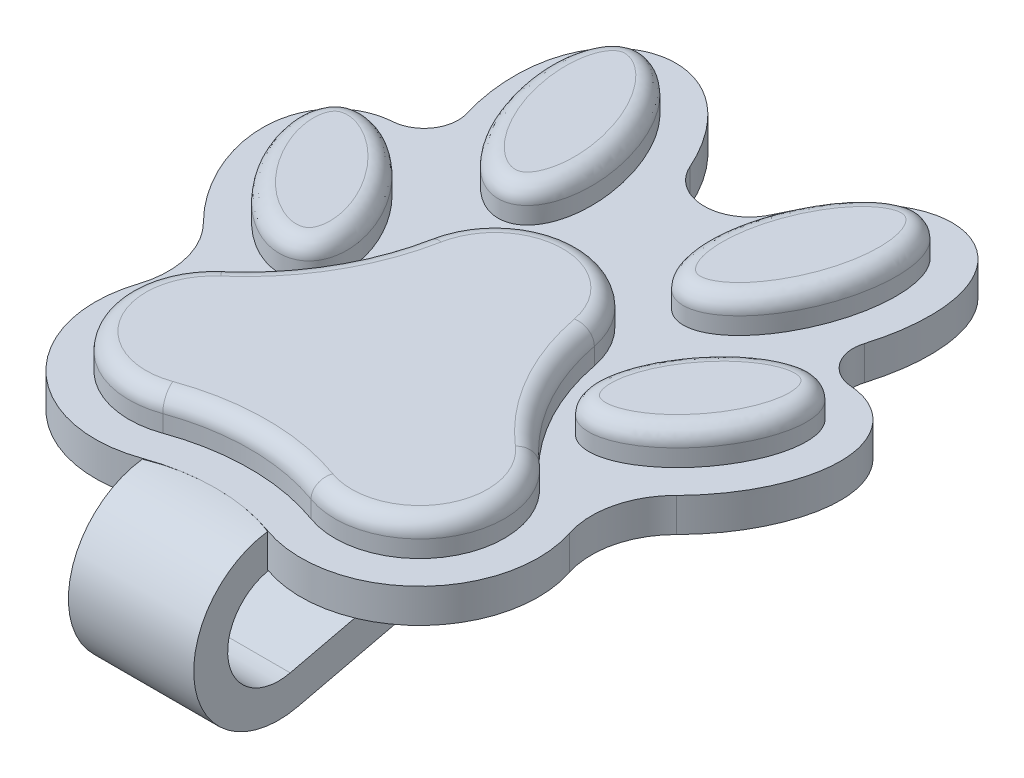
from build123d import *

# Parameters (mm, degrees)
SKETCH3_RX               = 5.238185387
SKETCH3_RY               = 2.857620548
BOSS_EXTRUDE1_DEPTH      = 2
SKETCH3_RX_2             = 5.80398495
SKETCH3_RY_2             = 3.052820099
BOSS_EXTRUDE1_2_DEPTH    = 2
BOSS_EXTRUDE1_3_DEPTH    = 2
BOSS_EXTRUDE1_4_DEPTH    = 2
BOSS_EXTRUDE1_5_DEPTH    = 2
BOSS_EXTRUDE2_DEPTH      = 2
FILLET1_R                = 1
FILLET2_R                = 1
BOSS_EXTRUDE3_DEPTH      = 3.69282
BOSS_EXTRUDE3_DEPTH_BACK = 3.692817


with BuildPart() as part:
    # Sketch3 → Boss-Extrude1 (new body)
    with BuildSketch(Plane(origin=(0, 0, 0), x_dir=(1, 0, 0), z_dir=(0, 1, 0))):
        with Locations(Location((11.150517056, 5.945805234), (0, 0, -126.593683689))):
            Ellipse(SKETCH3_RX, SKETCH3_RY)
    extrude(amount=BOSS_EXTRUDE1_DEPTH)



with BuildPart() as body_2:
    # Sketch3 → Boss-Extrude1 2 (new body)
    with BuildSketch(Plane(origin=(0, 0, 0), x_dir=(1, 0, 0), z_dir=(0, 1, 0))):
        with Locations(Location((6.797700407, 16.223268522), (0, 0, 71.016940581))):
            Ellipse(SKETCH3_RX_2, SKETCH3_RY_2)
    extrude(amount=BOSS_EXTRUDE1_2_DEPTH)


with BuildPart() as body_3:
    # Sketch3 → Boss-Extrude1 3 (new body)
    with BuildSketch(Plane(origin=(0, 0, 0), x_dir=(1, 0, 0), z_dir=(0, 1, 0))):
        with Locations(Location((-11.150517056, 5.945805234), (0, 0, 126.593683689))):
            Ellipse(SKETCH3_RX, SKETCH3_RY)
    extrude(amount=BOSS_EXTRUDE1_3_DEPTH)


with BuildPart() as body_4:
    # Sketch3 → Boss-Extrude1 4 (new body)
    with BuildSketch(Plane(origin=(0, 0, 0), x_dir=(1, 0, 0), z_dir=(0, 1, 0))):
        with Locations(Location((-6.797700407, 16.223268522), (0, 0, 108.983059419))):
            Ellipse(SKETCH3_RX_2, SKETCH3_RY_2)
    extrude(amount=BOSS_EXTRUDE1_4_DEPTH)


with BuildPart() as body_5:
    # Sketch3 → Boss-Extrude1 5 (new body)
    with BuildSketch(Plane(origin=(0, 0, 0), x_dir=(1, 0, 0), z_dir=(0, 1, 0))):
        with BuildLine():
            ThreePointArc((4.909730386, 5.945805234), (0, 10), (-4.909730386, 5.945805234))
            ThreePointArc((-4.909730386, 5.945805234), (-6.478137096, 1.740154196), (-9.336134379, -1.720951377))
            ThreePointArc((-9.336134379, -1.720951377), (-10.377214285, -8.025957316), (-4.36977754, -10.204867827))
            ThreePointArc((-4.36977754, -10.204867827), (0, -9.442836556), (4.36977754, -10.204867827))
            ThreePointArc((4.36977754, -10.204867827), (10.377214285, -8.025957316), (9.336134379, -1.720951377))
            ThreePointArc((9.336134379, -1.720951377), (6.478137096, 1.740154196), (4.909730386, 5.945805234))
        make_face()
    extrude(amount=BOSS_EXTRUDE1_5_DEPTH)

    # Fillet2
    fillet2_edges = [body_5.edges().sort_by_distance(p)[0] for p in [
        (0, 2, 9.442836556),
        (10.377214285, 2, 8.025957316),
        (6.478137096, 2, -1.740154196),
        (0, 2, -10),
        (-6.478137096, 2, -1.740154196),
        (-10.377214285, 2, 8.025957316),
    ]]
    fillet(fillet2_edges, radius=FILLET2_R)



with BuildPart() as part_1:
    add(part.part)

    add(body_2.part)  # Boss-Extrude2 merges body 2

    add(body_3.part)  # Boss-Extrude2 merges body 3

    add(body_4.part)  # Boss-Extrude2 merges body 4
    # Sketch4 → Boss-Extrude2 (add)
    with BuildSketch(Plane.XZ):
        with BuildLine():
            ThreePointArc((-2.422583286, -18.894030313), (0.000865066, -17.331984008), (2.423296766, -18.895606481))
            add(Edge.make_bspline(
                [(4.259153226, -8.843704897), (3.848822093, -8.984857544), (3.475668096, -9.194577762), (2.80258272, -9.740536498), (2.519377688, -10.063635935), (2.046515094, -10.787632114), (1.865696977, -11.174196166), (1.657021632, -11.78167321), (1.597848946, -11.989960488), (1.500208924, -12.408181258), (1.461545314, -12.618239281), (1.371623382, -13.250845699), (1.346160065, -13.675800885), (1.350835909, -14.530899224), (1.381528605, -14.961344228), (1.542708768, -16.228298191), (1.740149913, -17.052619047), (2.137117645, -18.209006226), (2.27329754, -18.556744576), (2.423296766, -18.895606481)],
                knots=[0, 0, 0, 0, 0.03125, 0.03125, 0.0625, 0.0625, 0.09375, 0.09375, 0.109375, 0.109375, 0.125, 0.125, 0.15625, 0.15625, 0.1875, 0.1875, 0.25, 0.25, 0.277125741, 0.277125741, 0.277125741, 0.277125741], degree=3))
            add(Edge.make_bspline(
                [(7.525496631, -9.197404066), (7.288046699, -9.070211825), (7.040823781, -8.960614284), (6.585417406, -8.805146453), (6.378401419, -8.750176975), (5.953486694, -8.672443347), (5.738286666, -8.650464151), (5.312217431, -8.642506316), (5.099864582, -8.656210626), (4.676607283, -8.721186769), (4.464318793, -8.773128573), (4.259153226, -8.843704897)],
                knots=[0.917943703, 0.917943703, 0.917943703, 0.917943703, 0.9375, 0.9375, 0.953125, 0.953125, 0.96875, 0.96875, 0.984375, 0.984375, 1, 1, 1, 1], degree=3))
            add(Edge.make_bspline(
                [(6.835571506, -0.134387799), (6.508634837, -0.377136482), (6.23222195, -0.66771727), (5.774564888, -1.338977401), (5.604263221, -1.704582747), (5.366656724, -2.479838377), (5.30303419, -2.877793392), (5.26250777, -3.678896429), (5.286336627, -4.08651054), (5.400774651, -4.879161695), (5.490929021, -5.268221593), (5.724470142, -6.0345981), (5.869041631, -6.413695041), (6.361925123, -7.50902984), (6.76923138, -8.192625986), (7.33628992, -8.95743613), (7.429669439, -9.078309767), (7.525496631, -9.197404066)],
                knots=[0, 0, 0, 0, 0.03125, 0.03125, 0.0625, 0.0625, 0.09375, 0.09375, 0.125, 0.125, 0.15625, 0.15625, 0.1875, 0.1875, 0.25, 0.25, 0.261882969, 0.261882969, 0.261882969, 0.261882969], degree=3))
            add(Edge.make_bspline(
                [(10.756413756, 0.307298484), (10.604962151, 0.358484778), (10.451627705, 0.403623023), (9.906498112, 0.538909259), (9.500025864, 0.593448409), (8.898079078, 0.59085851), (8.697688144, 0.576287783), (8.29748482, 0.516407806), (8.098568538, 0.470877767), (7.716268528, 0.350457854), (7.53106483, 0.275369234), (7.17307084, 0.094131557), (6.99903984, -0.013013458), (6.835571506, -0.134387799)],
                knots=[0.893791471, 0.893791471, 0.893791471, 0.893791471, 0.90625, 0.90625, 0.9375, 0.9375, 0.953125, 0.953125, 0.96875, 0.96875, 0.984375, 0.984375, 1, 1, 1, 1], degree=3))
            ThreePointArc((10.756413756, 0.307298484), (11.934063169, 1.689361926), (12.716623675, 3.327823568))
            ThreePointArc((12.716623675, 3.327823568), (10.937674915, 10.522900371), (3.692817425, 12.086814958))
            ThreePointArc((3.692817425, 12.086814958), (0, 11.442836556), (-3.692817425, 12.086814958))
            ThreePointArc((-3.692817425, 12.086814958), (-10.937580999, 10.522991529), (-12.716704899, 3.328072412))
            ThreePointArc((-12.716704899, 3.328072412), (-11.934071715, 1.689375095), (-10.756242865, 0.307144002))
            add(Edge.make_bspline(
                [(-6.835571506, -0.134387799), (-7.162508175, 0.108360883), (-7.520618759, 0.288910289), (-8.295560415, 0.532847942), (-8.694796776, 0.590121456), (-9.505640667, 0.593334485), (-9.904987756, 0.539131874), (-10.449525927, 0.404204792), (-10.603819821, 0.358699906), (-10.756242865, 0.307144002)],
                knots=[0, 0, 0, 0, 0.03125, 0.03125, 0.0625, 0.0625, 0.09375, 0.09375, 0.106212307, 0.106212307, 0.106212307, 0.106212307], degree=3))
            add(Edge.make_bspline(
                [(-7.524807959, -9.196645696), (-7.431722669, -9.080912461), (-7.340973676, -8.963498355), (-7.015139921, -8.524939953), (-6.794259063, -8.193576522), (-6.386917058, -7.50608607), (-6.199497449, -7.147842682), (-5.86908959, -6.414024526), (-5.726370522, -6.039854222), (-5.492643879, -5.274813988), (-5.401306629, -4.882962543), (-5.285721906, -4.082136489), (-5.262527509, -3.681433944), (-5.302810431, -2.879303578), (-5.368171711, -2.474430623), (-5.544759717, -1.898962712), (-5.616669277, -1.711351817), (-5.789745682, -1.34557474), (-5.890864689, -1.168330224), (-6.116714891, -0.837201942), (-6.242162752, -0.681633485), (-6.519200766, -0.391363385), (-6.672103171, -0.255762141), (-6.835571506, -0.134387799)],
                knots=[0.738354551, 0.738354551, 0.738354551, 0.738354551, 0.75, 0.75, 0.78125, 0.78125, 0.8125, 0.8125, 0.84375, 0.84375, 0.875, 0.875, 0.90625, 0.90625, 0.9375, 0.9375, 0.953125, 0.953125, 0.96875, 0.96875, 0.984375, 0.984375, 1, 1, 1, 1], degree=3))
            add(Edge.make_bspline(
                [(-4.259153226, -8.843704897), (-4.669484359, -8.702552249), (-5.092688433, -8.638327741), (-5.959203197, -8.654668766), (-6.381244156, -8.735165752), (-7.045781235, -8.962482676), (-7.290020606, -9.070750747), (-7.524807959, -9.196645696)],
                knots=[0, 0, 0, 0, 0.03125, 0.03125, 0.0625, 0.0625, 0.082012617, 0.082012617, 0.082012617, 0.082012617], degree=3))
            add(Edge.make_bspline(
                [(-2.422583286, -18.894030313), (-2.274039591, -18.55846166), (-2.140488008, -18.217638121), (-1.883317985, -17.471002965), (-1.764637159, -17.063460666), (-1.567884121, -16.234142339), (-1.489555118, -15.809953224), (-1.381408351, -14.960928341), (-1.351137746, -14.535687775), (-1.345930605, -13.683513975), (-1.371013021, -13.255013065), (-1.492220115, -12.402566786), (-1.587072104, -11.985707236), (-1.864910481, -11.176084249), (-2.050530814, -10.781005493), (-2.401464472, -10.244413389), (-2.530853665, -10.073721564), (-2.818024306, -9.751032761), (-2.974161059, -9.601314855), (-3.305167632, -9.332925271), (-3.48101207, -9.21309091), (-3.85467043, -9.003930518), (-4.05398766, -8.91428122), (-4.259153226, -8.843704897)],
                knots=[0.723029446, 0.723029446, 0.723029446, 0.723029446, 0.75, 0.75, 0.78125, 0.78125, 0.8125, 0.8125, 0.84375, 0.84375, 0.875, 0.875, 0.90625, 0.90625, 0.9375, 0.9375, 0.953125, 0.953125, 0.96875, 0.96875, 0.984375, 0.984375, 1, 1, 1, 1], degree=3))
        make_face()
        with BuildLine():
            add(Edge.make_bspline(
                [(4.259153226, -8.843704897), (3.848822093, -8.984857544), (3.475668096, -9.194577762), (2.80258272, -9.740536498), (2.519377688, -10.063635935), (2.046515094, -10.787632114), (1.865696977, -11.174196166), (1.657021632, -11.78167321), (1.597848946, -11.989960488), (1.500208924, -12.408181258), (1.461545314, -12.618239281), (1.371623382, -13.250845699), (1.346160065, -13.675800885), (1.350835909, -14.530899224), (1.381528605, -14.961344228), (1.542708768, -16.228298191), (1.740149913, -17.052619047), (2.137117645, -18.209006226), (2.27329754, -18.556744576), (2.423296766, -18.895606481)],
                knots=[0, 0, 0, 0, 0.03125, 0.03125, 0.0625, 0.0625, 0.09375, 0.09375, 0.109375, 0.109375, 0.125, 0.125, 0.15625, 0.15625, 0.1875, 0.1875, 0.25, 0.25, 0.277125741, 0.277125741, 0.277125741, 0.277125741], degree=3))
            add(Edge.make_bspline(
                [(2.423296766, -18.895606481), (2.446102985, -18.947127808), (2.469228665, -18.99844394), (2.670253606, -19.436628731), (2.866140335, -19.812373444), (3.297290074, -20.539434579), (3.532478648, -20.89079718), (3.920338406, -21.396080044), (4.055512814, -21.560854973), (4.339315963, -21.88205802), (4.488458139, -22.038908551), (4.951353672, -22.487042867), (5.282069157, -22.75867117), (5.821841442, -23.112517498), (6.009547511, -23.221456058), (6.392915178, -23.413334319), (6.589541417, -23.496993403), (6.993906127, -23.636701789), (7.20305022, -23.693024341), (7.627713174, -23.772229365), (7.840852508, -23.794884453), (8.268828573, -23.804586219), (8.485258623, -23.791399101), (8.912655723, -23.726778559), (9.120628984, -23.676096539), (9.525327582, -23.538639283), (9.723291247, -23.451161343), (10.101872212, -23.241567442), (10.279571191, -23.121377775), (10.613425455, -22.852389905), (10.770620063, -22.702318497), (11.058404368, -22.38046177), (11.188505756, -22.209701999), (11.424212634, -21.850719381), (11.530356425, -21.661230927), (11.71701754, -21.272749112), (11.79748735, -21.074398493), (12.006120231, -20.468872743), (12.102117377, -20.049286115), (12.223911974, -19.197005642), (12.249132929, -18.771219069), (12.244699605, -17.920189906), (12.214842475, -17.494949326), (12.107243224, -16.644942857), (12.029311627, -16.221380747), (11.870740881, -15.550728001), (11.802340262, -15.296990621), (11.726366992, -15.045809084)],
                knots=[0.277125741, 0.277125741, 0.277125741, 0.277125741, 0.28125, 0.28125, 0.3125, 0.3125, 0.34375, 0.34375, 0.359375, 0.359375, 0.375, 0.375, 0.40625, 0.40625, 0.421875, 0.421875, 0.4375, 0.4375, 0.453125, 0.453125, 0.46875, 0.46875, 0.484375, 0.484375, 0.5, 0.5, 0.515625, 0.515625, 0.53125, 0.53125, 0.546875, 0.546875, 0.5625, 0.5625, 0.578125, 0.578125, 0.59375, 0.59375, 0.625, 0.625, 0.65625, 0.65625, 0.6875, 0.6875, 0.71875, 0.71875, 0.738087773, 0.738087773, 0.738087773, 0.738087773], degree=3))
            add(Edge.make_bspline(
                [(11.726366992, -15.045809084), (11.679566832, -14.89107919), (11.629893108, -14.737319152), (11.439675549, -14.183645368), (11.282522364, -13.789337441), (10.927444668, -13.014482309), (10.728238084, -12.63187471), (10.336902789, -11.972974614), (10.15208074, -11.690813057), (9.953701489, -11.418578957)],
                knots=[0.738087773, 0.738087773, 0.738087773, 0.738087773, 0.75, 0.75, 0.78125, 0.78125, 0.8125, 0.8125, 0.837211833, 0.837211833, 0.837211833, 0.837211833], degree=3))
            add(Edge.make_bspline(
                [(7.525496631, -9.197404066), (7.681677137, -9.391505632), (7.844359383, -9.580880756), (8.282663007, -10.058136699), (8.567007139, -10.33645932), (9.16516306, -10.858099921), (9.478920923, -11.10148196), (9.857568435, -11.356018387), (9.905433222, -11.387514222), (9.953701489, -11.418578957)],
                knots=[0.261882969, 0.261882969, 0.261882969, 0.261882969, 0.28125, 0.28125, 0.3125, 0.3125, 0.34375, 0.34375, 0.348225609, 0.348225609, 0.348225609, 0.348225609], degree=3))
            add(Edge.make_bspline(
                [(7.525496631, -9.197404066), (7.288046699, -9.070211825), (7.040823781, -8.960614284), (6.585417406, -8.805146453), (6.378401419, -8.750176975), (5.953486694, -8.672443347), (5.738286666, -8.650464151), (5.312217431, -8.642506316), (5.099864582, -8.656210626), (4.676607283, -8.721186769), (4.464318793, -8.773128573), (4.259153226, -8.843704897)],
                knots=[0.917943703, 0.917943703, 0.917943703, 0.917943703, 0.9375, 0.9375, 0.953125, 0.953125, 0.96875, 0.96875, 0.984375, 0.984375, 1, 1, 1, 1], degree=3))
        make_face()
        with BuildLine():
            ThreePointArc((-2.43806278, -18.928858676), (-2.430385422, -18.911416766), (-2.422583286, -18.894030313))
            add(Edge.make_bspline(
                [(-2.422583286, -18.894030313), (-2.274039591, -18.55846166), (-2.140488008, -18.217638121), (-1.883317985, -17.471002965), (-1.764637159, -17.063460666), (-1.567884121, -16.234142339), (-1.489555118, -15.809953224), (-1.381408351, -14.960928341), (-1.351137746, -14.535687775), (-1.345930605, -13.683513975), (-1.371013021, -13.255013065), (-1.492220115, -12.402566786), (-1.587072104, -11.985707236), (-1.864910481, -11.176084249), (-2.050530814, -10.781005493), (-2.401464472, -10.244413389), (-2.530853665, -10.073721564), (-2.818024306, -9.751032761), (-2.974161059, -9.601314855), (-3.305167632, -9.332925271), (-3.48101207, -9.21309091), (-3.85467043, -9.003930518), (-4.05398766, -8.91428122), (-4.259153226, -8.843704897)],
                knots=[0.723029446, 0.723029446, 0.723029446, 0.723029446, 0.75, 0.75, 0.78125, 0.78125, 0.8125, 0.8125, 0.84375, 0.84375, 0.875, 0.875, 0.90625, 0.90625, 0.9375, 0.9375, 0.953125, 0.953125, 0.96875, 0.96875, 0.984375, 0.984375, 1, 1, 1, 1], degree=3))
            add(Edge.make_bspline(
                [(-4.259153226, -8.843704897), (-4.669484359, -8.702552249), (-5.092688433, -8.638327741), (-5.959203197, -8.654668766), (-6.381244156, -8.735165752), (-7.045781235, -8.962482676), (-7.290020606, -9.070750747), (-7.524807959, -9.196645696)],
                knots=[0, 0, 0, 0, 0.03125, 0.03125, 0.0625, 0.0625, 0.082012617, 0.082012617, 0.082012617, 0.082012617], degree=3))
            add(Edge.make_bspline(
                [(-9.953641188, -11.418558152), (-9.912087375, -11.39180526), (-9.870804756, -11.364716808), (-9.497525284, -11.115252657), (-9.181238051, -10.871229367), (-8.57620789, -10.345335972), (-8.28625388, -10.061816241), (-7.844838245, -9.581544725), (-7.681512557, -9.391477014), (-7.524807959, -9.196645696)],
                knots=[0.65239332, 0.65239332, 0.65239332, 0.65239332, 0.65625, 0.65625, 0.6875, 0.6875, 0.71875, 0.71875, 0.738354551, 0.738354551, 0.738354551, 0.738354551], degree=3))
            add(Edge.make_bspline(
                [(-9.953641188, -11.418558152), (-10.152194904, -11.691141063), (-10.337666184, -11.974362873), (-10.943696987, -12.99438717), (-11.295157775, -13.765725742), (-11.626958609, -14.72827236), (-11.678099385, -14.886392721), (-11.726224653, -15.045542672)],
                knots=[0.162907105, 0.162907105, 0.162907105, 0.162907105, 0.1875, 0.1875, 0.25, 0.25, 0.262134929, 0.262134929, 0.262134929, 0.262134929], degree=3))
            add(Edge.make_bspline(
                [(-11.726224653, -15.045542672), (-11.802032092, -15.296237381), (-11.870357186, -15.549486798), (-12.028519334, -16.217414115), (-12.105243611, -16.634150345), (-12.21262073, -17.472588265), (-12.243360665, -17.894280569), (-12.248429539, -18.531242319), (-12.243230235, -18.744305373), (-12.217089651, -19.172128111), (-12.196003459, -19.387536676), (-12.106758505, -20.025605621), (-12.01313527, -20.443205138), (-11.805277097, -21.054234043), (-11.724312884, -21.255594354), (-11.540118143, -21.642712337), (-11.436569678, -21.829630595), (-11.203726734, -22.188536454), (-11.073492201, -22.361604209), (-10.787425246, -22.685298135), (-10.633328897, -22.834281167), (-10.301891886, -23.105218695), (-10.12315126, -23.227969074), (-9.746447949, -23.439956599), (-9.551307751, -23.527944369), (-9.147690553, -23.668545259), (-8.937804988, -23.7213662), (-8.510400139, -23.789028939), (-8.296366635, -23.80359404), (-7.86768429, -23.796916417), (-7.651432803, -23.775309317), (-7.22654617, -23.6986092), (-7.018926907, -23.644024294), (-6.612257122, -23.506017272), (-6.412003621, -23.421928542), (-6.025852504, -23.230492373), (-5.840387758, -23.123622423), (-5.303390229, -22.77459124), (-4.969580751, -22.502856768), (-4.34924196, -21.905867897), (-4.067416461, -21.585704359), (-3.547362366, -20.912047155), (-3.309294929, -20.55843028), (-2.871203394, -19.82211214), (-2.672069236, -19.440243338), (-2.475406953, -19.011945937), (-2.45661935, -18.970442796), (-2.43806278, -18.928858676)],
                knots=[0.262134929, 0.262134929, 0.262134929, 0.262134929, 0.28125, 0.28125, 0.3125, 0.3125, 0.34375, 0.34375, 0.359375, 0.359375, 0.375, 0.375, 0.40625, 0.40625, 0.421875, 0.421875, 0.4375, 0.4375, 0.453125, 0.453125, 0.46875, 0.46875, 0.484375, 0.484375, 0.5, 0.5, 0.515625, 0.515625, 0.53125, 0.53125, 0.546875, 0.546875, 0.5625, 0.5625, 0.578125, 0.578125, 0.59375, 0.59375, 0.625, 0.625, 0.65625, 0.65625, 0.6875, 0.6875, 0.71875, 0.71875, 0.722095857, 0.722095857, 0.722095857, 0.722095857], degree=3))
        make_face()
        with BuildLine():
            add(Edge.make_bspline(
                [(11.726366992, -15.045809084), (11.679566832, -14.89107919), (11.629893108, -14.737319152), (11.439675549, -14.183645368), (11.282522364, -13.789337441), (10.927444668, -13.014482309), (10.728238084, -12.63187471), (10.336902789, -11.972974614), (10.15208074, -11.690813057), (9.953701489, -11.418578957)],
                knots=[0.738087773, 0.738087773, 0.738087773, 0.738087773, 0.75, 0.75, 0.78125, 0.78125, 0.8125, 0.8125, 0.837211833, 0.837211833, 0.837211833, 0.837211833], degree=3))
            ThreePointArc((11.726366992, -15.045809084), (11.992479268, -13.333953713), (13.495290649, -12.472082197))
            add(Edge.make_bspline(
                [(9.953701489, -11.418578957), (10.242456273, -11.604417218), (10.545650702, -11.774827337), (11.222248585, -12.092467361), (11.598677493, -12.231896672), (12.186738907, -12.379477134), (12.38658777, -12.418079061), (12.78540837, -12.469927318), (12.985501887, -12.483506307), (13.288975381, -12.483303254), (13.392163117, -12.479600812), (13.495290649, -12.472082197)],
                knots=[0.348225609, 0.348225609, 0.348225609, 0.348225609, 0.375, 0.375, 0.40625, 0.40625, 0.421875, 0.421875, 0.4375, 0.4375, 0.445483242, 0.445483242, 0.445483242, 0.445483242], degree=3))
        make_face()
        with BuildLine():
            add(Edge.make_bspline(
                [(6.835571506, -0.134387799), (6.508634837, -0.377136482), (6.23222195, -0.66771727), (5.774564888, -1.338977401), (5.604263221, -1.704582747), (5.366656724, -2.479838377), (5.30303419, -2.877793392), (5.26250777, -3.678896429), (5.286336627, -4.08651054), (5.400774651, -4.879161695), (5.490929021, -5.268221593), (5.724470142, -6.0345981), (5.869041631, -6.413695041), (6.361925123, -7.50902984), (6.76923138, -8.192625986), (7.33628992, -8.95743613), (7.429669439, -9.078309767), (7.525496631, -9.197404066)],
                knots=[0, 0, 0, 0, 0.03125, 0.03125, 0.0625, 0.0625, 0.09375, 0.09375, 0.125, 0.125, 0.15625, 0.15625, 0.1875, 0.1875, 0.25, 0.25, 0.261882969, 0.261882969, 0.261882969, 0.261882969], degree=3))
            add(Edge.make_bspline(
                [(9.953701489, -11.418578957), (9.901215029, -11.34655225), (9.847779556, -11.275220471), (9.533292397, -10.867086711), (9.249906272, -10.54469803), (8.629928649, -9.947217013), (8.298699671, -9.676928004), (7.805969076, -9.355804357), (7.667479996, -9.273458762), (7.525496631, -9.197404066)],
                knots=[0.837211833, 0.837211833, 0.837211833, 0.837211833, 0.84375, 0.84375, 0.875, 0.875, 0.90625, 0.90625, 0.917943703, 0.917943703, 0.917943703, 0.917943703], degree=3))
            add(Edge.make_bspline(
                [(9.953701489, -11.418578957), (10.242456273, -11.604417218), (10.545650702, -11.774827337), (11.222248585, -12.092467361), (11.598677493, -12.231896672), (12.186738907, -12.379477134), (12.38658777, -12.418079061), (12.78540837, -12.469927318), (12.985501887, -12.483506307), (13.288975381, -12.483303254), (13.392163117, -12.479600812), (13.495290649, -12.472082197)],
                knots=[0.348225609, 0.348225609, 0.348225609, 0.348225609, 0.375, 0.375, 0.40625, 0.40625, 0.421875, 0.421875, 0.4375, 0.4375, 0.445483242, 0.445483242, 0.445483242, 0.445483242], degree=3))
            add(Edge.make_bspline(
                [(13.495290649, -12.472082197), (13.594006901, -12.464885192), (13.692667989, -12.454191505), (13.991217998, -12.410499211), (14.187454097, -12.366341724), (14.571065681, -12.247195398), (14.759318906, -12.171783908), (15.122356471, -11.989142404), (15.293702761, -11.883823074), (15.778001144, -11.526938578), (16.064000961, -11.228849304), (16.518982821, -10.565658119), (16.694035962, -10.193009736), (16.931658618, -9.423517298), (16.997446051, -9.018495517), (17.038639676, -8.216676706), (17.015865237, -7.816410381), (16.901358233, -7.016900196), (16.810036038, -6.623292568), (16.577116387, -5.858695117), (16.435007514, -5.485345351), (16.106593693, -4.754065842), (15.919059928, -4.394499641), (15.510951975, -3.704464596), (15.289898803, -3.372469289), (14.815536904, -2.733188003), (14.562225566, -2.425904026), (14.178973011, -2.00824865), (14.062604934, -1.88697654), (13.943262833, -1.768239551)],
                knots=[0.445483242, 0.445483242, 0.445483242, 0.445483242, 0.453125, 0.453125, 0.46875, 0.46875, 0.484375, 0.484375, 0.5, 0.5, 0.53125, 0.53125, 0.5625, 0.5625, 0.59375, 0.59375, 0.625, 0.625, 0.65625, 0.65625, 0.6875, 0.6875, 0.71875, 0.71875, 0.75, 0.75, 0.78125, 0.78125, 0.794334665, 0.794334665, 0.794334665, 0.794334665], degree=3))
            add(Edge.make_bspline(
                [(13.943262833, -1.768239551), (13.777581165, -1.603397956), (13.606167499, -1.443442435), (13.126337853, -1.02555752), (12.809441651, -0.780712783), (12.144706252, -0.335694184), (11.796022851, -0.134920843), (11.209005742, 0.139128156), (10.984851512, 0.230093081), (10.756413756, 0.307298484)],
                knots=[0.794334665, 0.794334665, 0.794334665, 0.794334665, 0.8125, 0.8125, 0.84375, 0.84375, 0.875, 0.875, 0.893791471, 0.893791471, 0.893791471, 0.893791471], degree=3))
            add(Edge.make_bspline(
                [(10.756413756, 0.307298484), (10.604962151, 0.358484778), (10.451627705, 0.403623023), (9.906498112, 0.538909259), (9.500025864, 0.593448409), (8.898079078, 0.59085851), (8.697688144, 0.576287783), (8.29748482, 0.516407806), (8.098568538, 0.470877767), (7.716268528, 0.350457854), (7.53106483, 0.275369234), (7.17307084, 0.094131557), (6.99903984, -0.013013458), (6.835571506, -0.134387799)],
                knots=[0.893791471, 0.893791471, 0.893791471, 0.893791471, 0.90625, 0.90625, 0.9375, 0.9375, 0.953125, 0.953125, 0.96875, 0.96875, 0.984375, 0.984375, 1, 1, 1, 1], degree=3))
        make_face()
        with BuildLine():
            add(Edge.make_bspline(
                [(9.953701489, -11.418578957), (9.901215029, -11.34655225), (9.847779556, -11.275220471), (9.533292397, -10.867086711), (9.249906272, -10.54469803), (8.629928649, -9.947217013), (8.298699671, -9.676928004), (7.805969076, -9.355804357), (7.667479996, -9.273458762), (7.525496631, -9.197404066)],
                knots=[0.837211833, 0.837211833, 0.837211833, 0.837211833, 0.84375, 0.84375, 0.875, 0.875, 0.90625, 0.90625, 0.917943703, 0.917943703, 0.917943703, 0.917943703], degree=3))
            add(Edge.make_bspline(
                [(7.525496631, -9.197404066), (7.681677137, -9.391505632), (7.844359383, -9.580880756), (8.282663007, -10.058136699), (8.567007139, -10.33645932), (9.16516306, -10.858099921), (9.478920923, -11.10148196), (9.857568435, -11.356018387), (9.905433222, -11.387514222), (9.953701489, -11.418578957)],
                knots=[0.261882969, 0.261882969, 0.261882969, 0.261882969, 0.28125, 0.28125, 0.3125, 0.3125, 0.34375, 0.34375, 0.348225609, 0.348225609, 0.348225609, 0.348225609], degree=3))
        make_face()
        with BuildLine():
            ThreePointArc((-13.494070316, -12.472027576), (-11.992097489, -13.334223012), (-11.726224653, -15.045542672))
            add(Edge.make_bspline(
                [(-9.953641188, -11.418558152), (-10.152194904, -11.691141063), (-10.337666184, -11.974362873), (-10.943696987, -12.99438717), (-11.295157775, -13.765725742), (-11.626958609, -14.72827236), (-11.678099385, -14.886392721), (-11.726224653, -15.045542672)],
                knots=[0.162907105, 0.162907105, 0.162907105, 0.162907105, 0.1875, 0.1875, 0.25, 0.25, 0.262134929, 0.262134929, 0.262134929, 0.262134929], degree=3))
            add(Edge.make_bspline(
                [(-13.494070316, -12.472027576), (-13.399400085, -12.478982917), (-13.304615329, -12.482717272), (-12.807422998, -12.485739611), (-12.400685025, -12.431565351), (-11.621224397, -12.239077818), (-11.2446545, -12.101502678), (-10.557621838, -11.781671299), (-10.248790634, -11.608579254), (-9.953641188, -11.418558152)],
                knots=[0.555164011, 0.555164011, 0.555164011, 0.555164011, 0.5625, 0.5625, 0.59375, 0.59375, 0.625, 0.625, 0.65239332, 0.65239332, 0.65239332, 0.65239332], degree=3))
        make_face()
        with BuildLine():
            add(Edge.make_bspline(
                [(-7.524807959, -9.196645696), (-7.666039097, -9.272375017), (-7.803850157, -9.354482373), (-8.118032442, -9.559105372), (-8.292820062, -9.686911024), (-8.627084472, -9.956557998), (-8.78679261, -10.09837675), (-9.246861334, -10.541788075), (-9.528366439, -10.861147069), (-9.845188704, -11.271765582), (-9.899894249, -11.344772088), (-9.953641188, -11.418558152)],
                knots=[0.082012617, 0.082012617, 0.082012617, 0.082012617, 0.09375, 0.09375, 0.109375, 0.109375, 0.125, 0.125, 0.15625, 0.15625, 0.162907105, 0.162907105, 0.162907105, 0.162907105], degree=3))
            add(Edge.make_bspline(
                [(-7.524807959, -9.196645696), (-7.431722669, -9.080912461), (-7.340973676, -8.963498355), (-7.015139921, -8.524939953), (-6.794259063, -8.193576522), (-6.386917058, -7.50608607), (-6.199497449, -7.147842682), (-5.86908959, -6.414024526), (-5.726370522, -6.039854222), (-5.492643879, -5.274813988), (-5.401306629, -4.882962543), (-5.285721906, -4.082136489), (-5.262527509, -3.681433944), (-5.302810431, -2.879303578), (-5.368171711, -2.474430623), (-5.544759717, -1.898962712), (-5.616669277, -1.711351817), (-5.789745682, -1.34557474), (-5.890864689, -1.168330224), (-6.116714891, -0.837201942), (-6.242162752, -0.681633485), (-6.519200766, -0.391363385), (-6.672103171, -0.255762141), (-6.835571506, -0.134387799)],
                knots=[0.738354551, 0.738354551, 0.738354551, 0.738354551, 0.75, 0.75, 0.78125, 0.78125, 0.8125, 0.8125, 0.84375, 0.84375, 0.875, 0.875, 0.90625, 0.90625, 0.9375, 0.9375, 0.953125, 0.953125, 0.96875, 0.96875, 0.984375, 0.984375, 1, 1, 1, 1], degree=3))
            add(Edge.make_bspline(
                [(-6.835571506, -0.134387799), (-7.162508175, 0.108360883), (-7.520618759, 0.288910289), (-8.295560415, 0.532847942), (-8.694796776, 0.590121456), (-9.505640667, 0.593334485), (-9.904987756, 0.539131874), (-10.449525927, 0.404204792), (-10.603819821, 0.358699906), (-10.756242865, 0.307144002)],
                knots=[0, 0, 0, 0, 0.03125, 0.03125, 0.0625, 0.0625, 0.09375, 0.09375, 0.106212307, 0.106212307, 0.106212307, 0.106212307], degree=3))
            add(Edge.make_bspline(
                [(-10.756242865, 0.307144002), (-10.986029963, 0.229420309), (-11.211565101, 0.137944214), (-11.792538339, -0.133312236), (-12.138891655, -0.332145823), (-12.804959869, -0.777373337), (-13.126036324, -1.02541631), (-13.606108915, -1.443320387), (-13.778337057, -1.60372561), (-13.944914661, -1.769317237)],
                knots=[0.106212307, 0.106212307, 0.106212307, 0.106212307, 0.125, 0.125, 0.15625, 0.15625, 0.1875, 0.1875, 0.20592899, 0.20592899, 0.20592899, 0.20592899], degree=3))
            add(Edge.make_bspline(
                [(-13.944914661, -1.769317237), (-14.343267645, -2.16531236), (-14.709306484, -2.590967357), (-15.284572058, -3.364638502), (-15.509006213, -3.701480285), (-15.916576299, -4.389997976), (-16.100757718, -4.742690862), (-16.427088852, -5.466159876), (-16.569315487, -5.836902911), (-16.803977981, -6.599810397), (-16.896976963, -6.995752406), (-17.013696878, -7.792348788), (-17.038287013, -8.193016457), (-17.009466693, -8.798628221), (-16.988613753, -9.001100025), (-16.922889785, -9.397870076), (-16.878012728, -9.593338371), (-16.761565159, -9.977794967), (-16.689388441, -10.168075079), (-16.517230061, -10.534949118), (-16.418200162, -10.710025014), (-16.193189745, -11.042777183), (-16.066550761, -11.20117143), (-15.786710108, -11.495863475), (-15.636331882, -11.629422831), (-15.154622298, -11.98979395), (-14.786551222, -12.177348725), (-14.110069367, -12.392453668), (-13.802678331, -12.449354411), (-13.494070316, -12.472027576)],
                knots=[0.20592899, 0.20592899, 0.20592899, 0.20592899, 0.25, 0.25, 0.28125, 0.28125, 0.3125, 0.3125, 0.34375, 0.34375, 0.375, 0.375, 0.40625, 0.40625, 0.421875, 0.421875, 0.4375, 0.4375, 0.453125, 0.453125, 0.46875, 0.46875, 0.484375, 0.484375, 0.5, 0.5, 0.53125, 0.53125, 0.555164011, 0.555164011, 0.555164011, 0.555164011], degree=3))
            add(Edge.make_bspline(
                [(-13.494070316, -12.472027576), (-13.399400085, -12.478982917), (-13.304615329, -12.482717272), (-12.807422998, -12.485739611), (-12.400685025, -12.431565351), (-11.621224397, -12.239077818), (-11.2446545, -12.101502678), (-10.557621838, -11.781671299), (-10.248790634, -11.608579254), (-9.953641188, -11.418558152)],
                knots=[0.555164011, 0.555164011, 0.555164011, 0.555164011, 0.5625, 0.5625, 0.59375, 0.59375, 0.625, 0.625, 0.65239332, 0.65239332, 0.65239332, 0.65239332], degree=3))
        make_face()
        with BuildLine():
            add(Edge.make_bspline(
                [(-9.953641188, -11.418558152), (-9.912087375, -11.39180526), (-9.870804756, -11.364716808), (-9.497525284, -11.115252657), (-9.181238051, -10.871229367), (-8.57620789, -10.345335972), (-8.28625388, -10.061816241), (-7.844838245, -9.581544725), (-7.681512557, -9.391477014), (-7.524807959, -9.196645696)],
                knots=[0.65239332, 0.65239332, 0.65239332, 0.65239332, 0.65625, 0.65625, 0.6875, 0.6875, 0.71875, 0.71875, 0.738354551, 0.738354551, 0.738354551, 0.738354551], degree=3))
            add(Edge.make_bspline(
                [(-7.524807959, -9.196645696), (-7.666039097, -9.272375017), (-7.803850157, -9.354482373), (-8.118032442, -9.559105372), (-8.292820062, -9.686911024), (-8.627084472, -9.956557998), (-8.78679261, -10.09837675), (-9.246861334, -10.541788075), (-9.528366439, -10.861147069), (-9.845188704, -11.271765582), (-9.899894249, -11.344772088), (-9.953641188, -11.418558152)],
                knots=[0.082012617, 0.082012617, 0.082012617, 0.082012617, 0.09375, 0.09375, 0.109375, 0.109375, 0.125, 0.125, 0.15625, 0.15625, 0.162907105, 0.162907105, 0.162907105, 0.162907105], degree=3))
        make_face()
        with BuildLine():
            add(Edge.make_bspline(
                [(13.943262833, -1.768239551), (13.777581165, -1.603397956), (13.606167499, -1.443442435), (13.126337853, -1.02555752), (12.809441651, -0.780712783), (12.144706252, -0.335694184), (11.796022851, -0.134920843), (11.209005742, 0.139128156), (10.984851512, 0.230093081), (10.756413756, 0.307298484)],
                knots=[0.794334665, 0.794334665, 0.794334665, 0.794334665, 0.8125, 0.8125, 0.84375, 0.84375, 0.875, 0.875, 0.893791471, 0.893791471, 0.893791471, 0.893791471], degree=3))
            ThreePointArc((13.943262833, -1.768239551), (12.608639671, 0.606171863), (12.716623675, 3.327823568))
            ThreePointArc((12.716623675, 3.327823568), (11.934063169, 1.689361926), (10.756413756, 0.307298484))
        make_face()
        with BuildLine():
            ThreePointArc((-12.716704899, 3.328072412), (-12.609050532, 0.605470585), (-13.944914661, -1.769317237))
            add(Edge.make_bspline(
                [(-10.756242865, 0.307144002), (-10.986029963, 0.229420309), (-11.211565101, 0.137944214), (-11.792538339, -0.133312236), (-12.138891655, -0.332145823), (-12.804959869, -0.777373337), (-13.126036324, -1.02541631), (-13.606108915, -1.443320387), (-13.778337057, -1.60372561), (-13.944914661, -1.769317237)],
                knots=[0.106212307, 0.106212307, 0.106212307, 0.106212307, 0.125, 0.125, 0.15625, 0.15625, 0.1875, 0.1875, 0.20592899, 0.20592899, 0.20592899, 0.20592899], degree=3))
            ThreePointArc((-10.756242865, 0.307144002), (-11.934071715, 1.689375095), (-12.716704899, 3.328072412))
        make_face()
    extrude(amount=BOSS_EXTRUDE2_DEPTH)

    # Fillet1
    fillet1_edges = [part_1.edges().sort_by_distance(p)[0] for p in [
        (-4.895529997, 2, -10.739893876),
        (4.923976606, 2, -10.73010833),
        (-8.018582444, 2, -1.747084484),
        (14.263876903, 2, -10.158317645),
    ]]
    fillet(fillet1_edges, radius=FILLET1_R)


with BuildPart() as body_5_1:
    add(body_5.part)

    add(part_1.part)  # Boss-Extrude3 merges part
    # Sketch5 → Boss-Extrude3 (add, two sides)
    with BuildSketch(Plane(origin=(0, 0, 0), x_dir=(0, 0, -1), z_dir=(1, 0, 0))) as boss_extrude3_sk:
        with BuildLine():
            Line((17.108685421, -5.741805887), (17.331983867, -3.754310528))
            Line((17.331983867, -3.754310528), (10.331983867, -2.967848755))
            Line((10.331983867, -2.967848755), (-10.756953398, -7.920541781))
            ThreePointArc((-10.756953398, -7.920541781), (-14.422905796, -5.345235179), (-11.442836556, -2))
            Line((-11.442836556, -2), (-11.442836556, 0))
            ThreePointArc((-11.442836556, 0), (-16.409618622, -5.575391966), (-10.299697958, -9.867569634))
            Line((-10.299697958, -9.867569634), (10.452462193, -4.993968013))
            Line((10.452462193, -4.993968013), (17.108685421, -5.741805887))
        make_face()
    extrude(amount=BOSS_EXTRUDE3_DEPTH)
    extrude(boss_extrude3_sk.sketch, amount=-BOSS_EXTRUDE3_DEPTH_BACK)


solid = body_5_1.part
